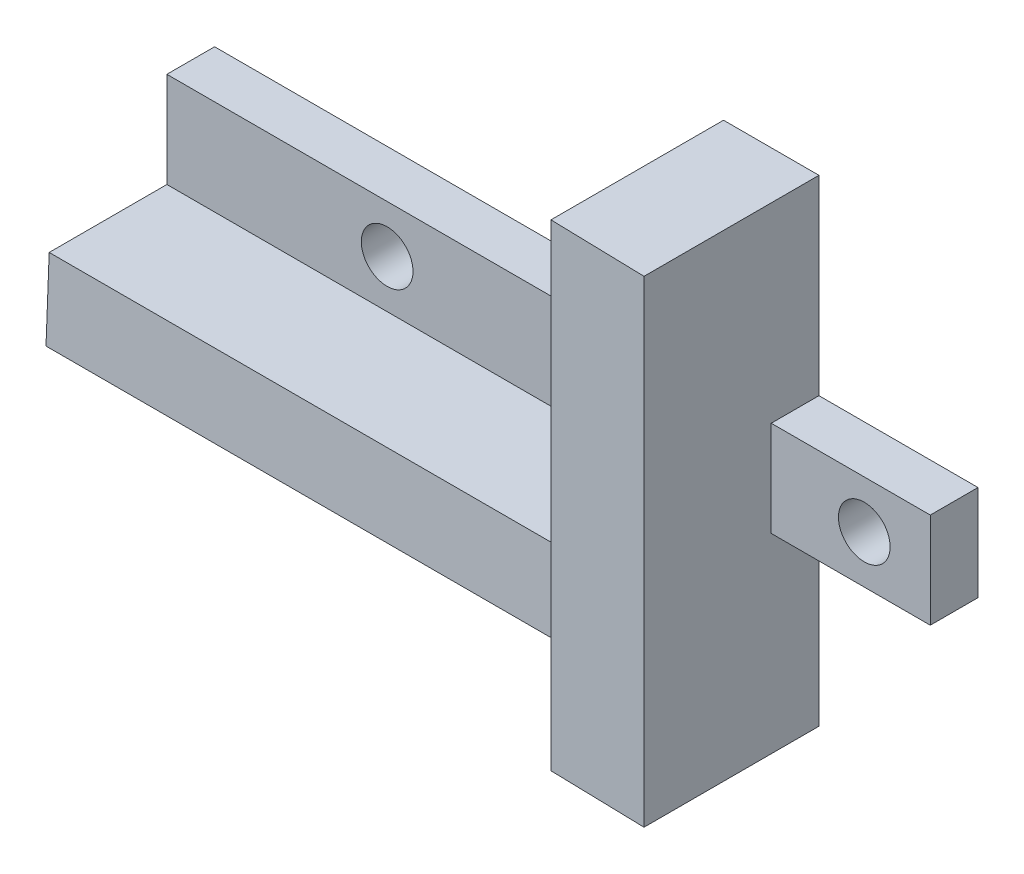
from build123d import *

# Parameters (mm, degrees)
BOSS_EXTRU_1_DEPTH      = 3
ESQUISSE2_R             = 1.625
ENL_V_MAT_EXTRU_1_DEPTH = 4
BOSS_EXTRU_2_DEPTH      = 10
BOSS_EXTRU_2_DEPTH_BACK = 3
ENL_V_MAT_EXTRU_2_DEPTH = 32
ESQUISSE7_W             = 6
ESQUISSE7_H             = 30
ENL_V_MAT_EXTRU_4_DEPTH = 2
ENL_V_MAT_EXTRU_5_DEPTH = 30


with BuildPart() as part:
    # Esquisse1 → Boss.-Extru.1 (new body)
    with BuildSketch(Plane.XY):
        Polygon((32, -6), (32, -18), (38, -18), (38, -6), (48, -6), (48, 0), (38, 0), (38, 12), (32, 12), (32, 0), (0, 0), (0, -6), align=None)
    extrude(amount=BOSS_EXTRU_1_DEPTH)

    # Esquisse2 → Enlèv. mat.-Extru.1 (cut, through all)
    with BuildSketch(Plane.XY.offset(3)):
        with Locations((13.85, -3)):
            Circle(ESQUISSE2_R)
        with Locations((43.85, -3)):
            Circle(ESQUISSE2_R)
    extrude(amount=-ENL_V_MAT_EXTRU_1_DEPTH, mode=Mode.SUBTRACT)

    # Esquisse3 → Boss.-Extru.2 (add, two sides)
    with BuildSketch(Plane.XY.offset(3)) as boss_extru_2_sk:
        Polygon((38, 12), (32, 12), (32, -6), (0, -6), (0, -11), (32, -11), (32, -18), (38, -18), align=None)
    extrude(amount=BOSS_EXTRU_2_DEPTH)
    extrude(boss_extru_2_sk.sketch, amount=-BOSS_EXTRU_2_DEPTH_BACK)

    # Esquisse4 → Enlèv. mat.-Extru.2 (cut)
    with BuildSketch(Plane.ZY):
        Polygon((13, -6), (13, -11), (10.6, -11), (10.4, -6), align=None)
    extrude(amount=-ENL_V_MAT_EXTRU_2_DEPTH, mode=Mode.SUBTRACT)

    # Esquisse7 → Enlèv. mat.-Extru.4 (cut)
    with BuildSketch(Plane.XY.offset(13)):
        with Locations((35, -3)):
            Rectangle(ESQUISSE7_W, ESQUISSE7_H)
    extrude(amount=-ENL_V_MAT_EXTRU_4_DEPTH, mode=Mode.SUBTRACT)

    # Esquisse8 → Enlèv. mat.-Extru.5 (cut)
    with BuildSketch(Plane.XZ.offset(18)):
        Polygon((32, 11), (32, 10.85), (38, 11), align=None)
    extrude(amount=-ENL_V_MAT_EXTRU_5_DEPTH, mode=Mode.SUBTRACT)


solid = part.part
